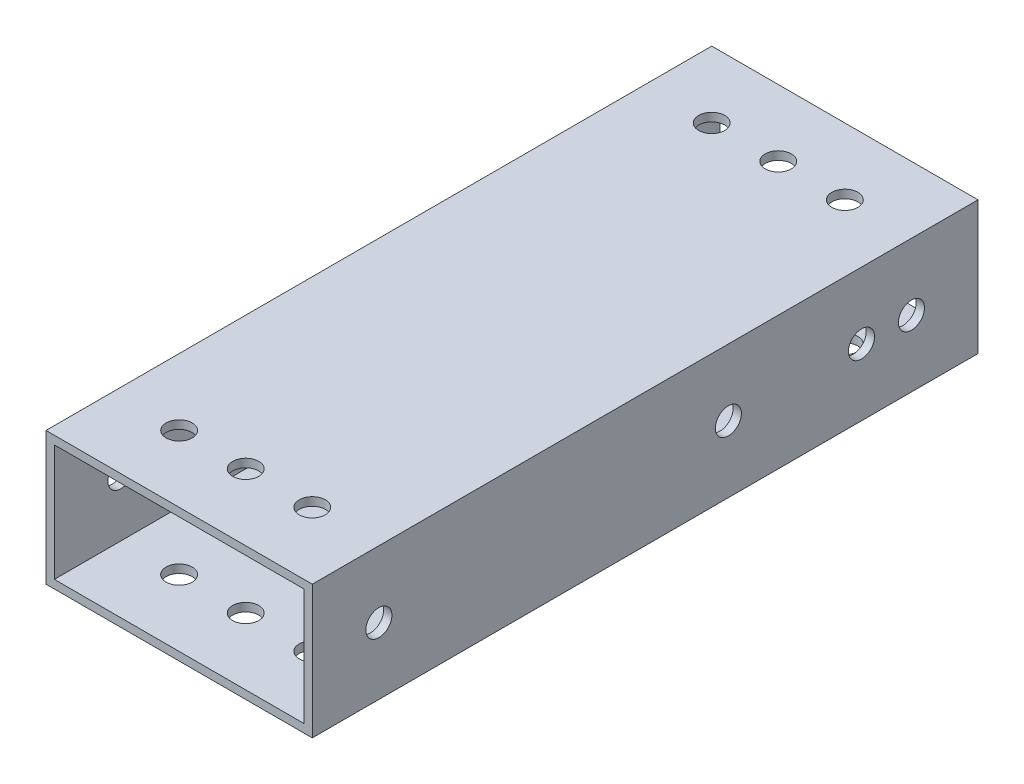
from build123d import *

# Parameters (mm, degrees)
SKETCH1_W           = 50.8
SKETCH1_H           = 25.4
SKETCH1_W_2         = 47.625
SKETCH1_H_2         = 22.225
BOSS_EXTRUDE1_DEPTH = 63.5
SKETCH2_R           = 2.4892
CUT_EXTRUDE1_DEPTH  = 26.4
SKETCH3_R           = 2.4892
CUT_EXTRUDE2_DEPTH  = 51.8
SKETCH5_R           = 2.4892
CUT_EXTRUDE3_DEPTH  = 51.8


with BuildPart() as part:
    # Sketch1 → Boss-Extrude1 (new body, symmetric)
    with BuildSketch(Plane.XY):
        Rectangle(SKETCH1_W, SKETCH1_H)
        Rectangle(SKETCH1_W_2, SKETCH1_H_2, mode=Mode.SUBTRACT)
    extrude(amount=BOSS_EXTRUDE1_DEPTH, both=True)

    # Sketch2 → Cut-Extrude1 (cut, through all)
    with BuildSketch(Plane(origin=(0, 12.7, 0), x_dir=(1, 0, 0), z_dir=(0, 1, 0))):
        with Locations((-12.7, 50.8)):
            Circle(SKETCH2_R)
        with Locations((0, 50.8)):
            Circle(SKETCH2_R)
        with Locations((12.7, 50.8)):
            Circle(SKETCH2_R)
        with Locations((12.7, -50.8)):
            Circle(SKETCH2_R)
        with Locations((0, -50.8)):
            Circle(SKETCH2_R)
        with Locations((-12.7, -50.8)):
            Circle(SKETCH2_R)
    extrude(amount=-CUT_EXTRUDE1_DEPTH, mode=Mode.SUBTRACT)

    # Sketch3 → Cut-Extrude2 (cut, through all)
    with BuildSketch(Plane.ZY.offset(25.4)):
        with Locations((-50.8, 0)):
            Circle(SKETCH3_R)
        with Locations((50.8, 0)):
            Circle(SKETCH3_R)
    extrude(amount=-CUT_EXTRUDE2_DEPTH, mode=Mode.SUBTRACT)

    # Sketch5 → Cut-Extrude3 (cut, through all)
    with BuildSketch(Plane(origin=(25.4, 0, 0), x_dir=(0, 0, -1), z_dir=(1, 0, 0))):
        with Locations((41.275, 0)):
            Circle(SKETCH5_R)
        with Locations((15.875, 0)):
            Circle(SKETCH5_R)
    extrude(amount=-CUT_EXTRUDE3_DEPTH, mode=Mode.SUBTRACT)


solid = part.part
